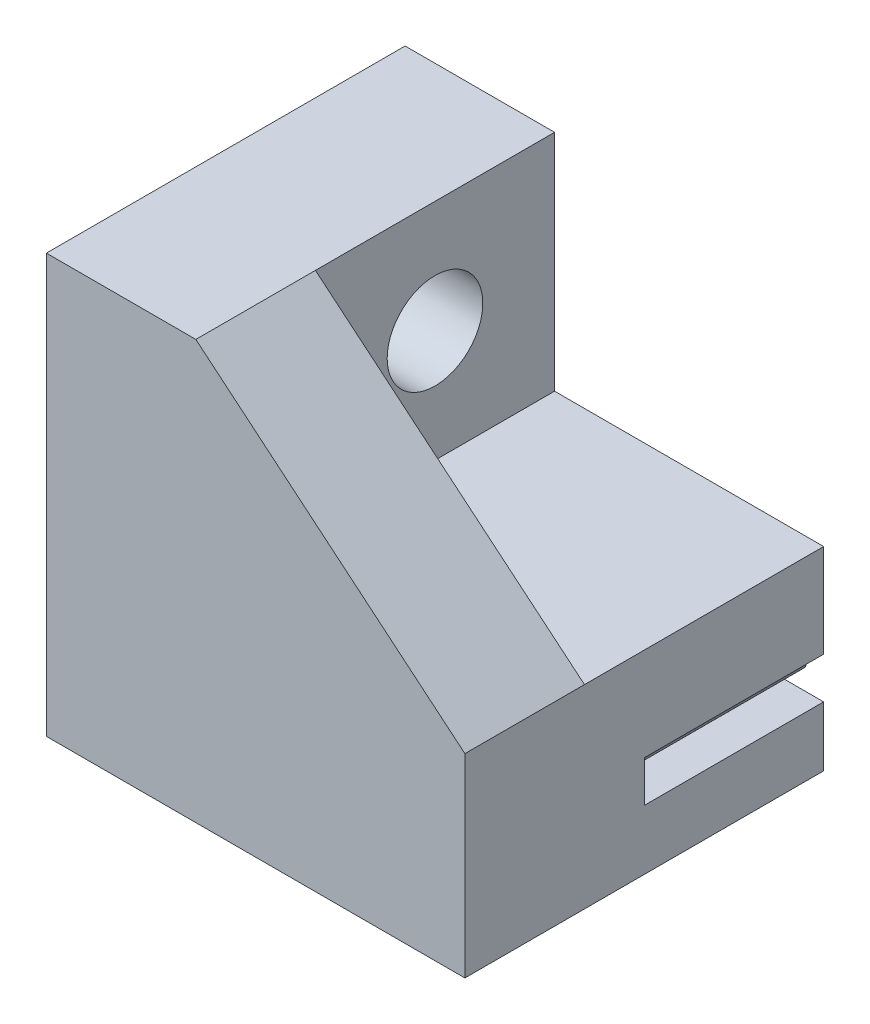
from build123d import *

# Parameters (mm, degrees)
SKETCH3_W           = 14
SKETCH3_H           = 6.5
BOSS_EXTRUDE2_DEPTH = 8
CUT_EXTRUDE1_DEPTH  = 6
LPATTERN2_COUNT     = 7
LPATTERN2_PITCH     = 2
SKETCH4_W           = 8
SKETCH4_H           = 7.5
BOSS_EXTRUDE3_DEPTH = 5
CUT_EXTRUDE2_DEPTH  = 2
SKETCH6_R           = 1.6
CUT_EXTRUDE3_DEPTH  = 10
BOSS_EXTRUDE4_DEPTH = 4


with BuildPart() as part:
    # Sketch3 → Boss-Extrude2 (new body)
    with BuildSketch(Plane.XY):
        with Locations((7, 1.25)):
            Rectangle(SKETCH3_W, SKETCH3_H)
    extrude(amount=BOSS_EXTRUDE2_DEPTH)

    # Sketch1 → Cut-Extrude1 (cut)
    with BuildSketch(Plane.XY):
        with BuildLine():
            Line((0.740175425, 0.63), (1.259824575, 0.63))
            ThreePointArc((1.259824575, 0.63), (1.358731646, 0.667228588), (1.408543109, 0.760434783))
            ThreePointArc((1.408543109, 0.760434783), (1.442388286, 0.918062154), (1.501123596, 1.068202247))
            ThreePointArc((1.501123596, 1.068202247), (1.705850588, 1.295639059), (2, 1.38))
            Line((2, 1.38), (2, 0))
            Line((2, 0), (0, 0))
            Line((0, 0), (0, 1.38))
            ThreePointArc((0, 1.38), (0.294149412, 1.295639059), (0.498876404, 1.068202247))
            ThreePointArc((0.498876404, 1.068202247), (0.557611714, 0.918062154), (0.591456891, 0.760434783))
            ThreePointArc((0.591456891, 0.760434783), (0.641268354, 0.667228588), (0.740175425, 0.63))
        make_face()
    cut_extrude1 = extrude(amount=CUT_EXTRUDE1_DEPTH, mode=Mode.SUBTRACT)

    # LPattern2: Cut-Extrude1 ×7
    with Locations(*[(i * LPATTERN2_PITCH, 0, 0) for i in range(1, LPATTERN2_COUNT)]):
        add(cut_extrude1, mode=Mode.SUBTRACT)

    # Sketch4 → Boss-Extrude3 (add)
    with BuildSketch(Plane.ZY):
        with Locations((4, 8.25)):
            Rectangle(SKETCH4_W, SKETCH4_H)
    extrude(amount=-BOSS_EXTRUDE3_DEPTH)

    # Sketch5 → Cut-Extrude2 (cut)
    with BuildSketch(Plane.ZY):
        Polygon((1.25, 9.83771324), (1.25, 6.66228676), (4, 5.074573519), (6.75, 6.66228676), (6.75, 9.83771324), (4, 11.425426481), align=None)
    extrude(amount=-CUT_EXTRUDE2_DEPTH, mode=Mode.SUBTRACT)

    # Sketch6 → Cut-Extrude3 (cut)
    with BuildSketch(Plane.ZY.offset(-2)):
        with Locations((4, 8.25)):
            Circle(SKETCH6_R)
    extrude(amount=-CUT_EXTRUDE3_DEPTH, mode=Mode.SUBTRACT)

    # Sketch7 → Boss-Extrude4 (add)
    with BuildSketch(Plane.XY.offset(8)):
        Polygon((14, -2), (14, 4.5), (5, 12), (0, 12), (0, -2), align=None)
    extrude(amount=BOSS_EXTRUDE4_DEPTH)


solid = part.part
